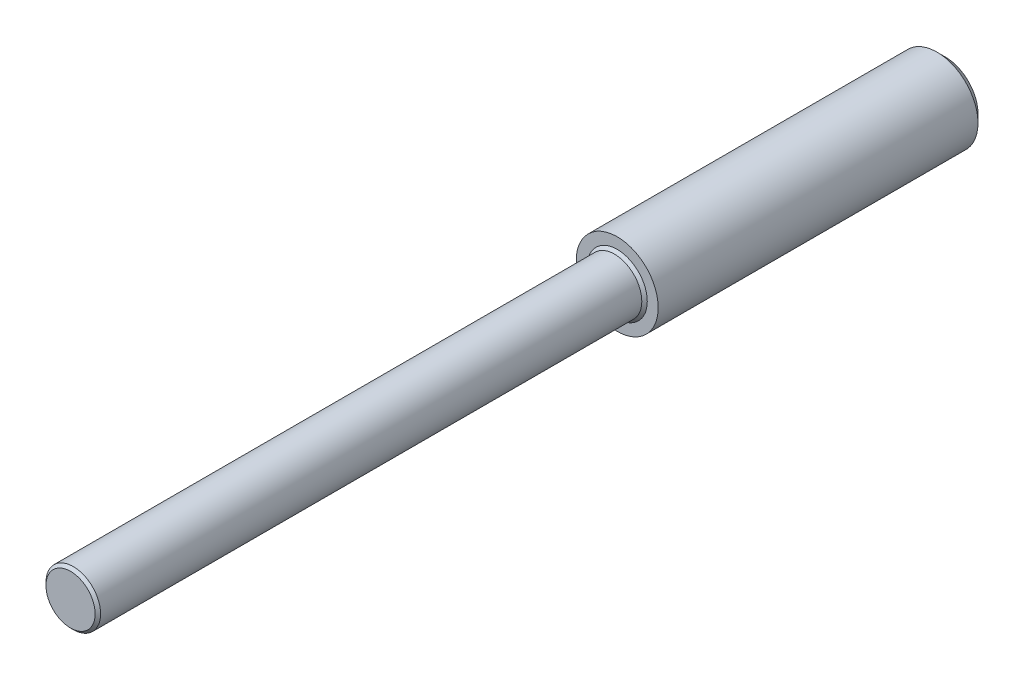
from build123d import *

# Parameters (mm, degrees)
SKETCH1_R           = 1.5
BOSS_EXTRUDE1_DEPTH = 12
SKETCH2_R           = 1
BOSS_EXTRUDE2_DEPTH = 20
CHAMFER1_SIZE       = 0.3
CHAMFER2_SIZE       = 0.1


with BuildPart() as part:
    # Sketch1 → Boss-Extrude1 (new body)
    with BuildSketch(Plane.XY):
        Circle(SKETCH1_R)
    extrude(amount=BOSS_EXTRUDE1_DEPTH)

    # Sketch2 → Boss-Extrude2 (add)
    with BuildSketch(Plane.XY.offset(12)):
        Circle(SKETCH2_R)
    extrude(amount=BOSS_EXTRUDE2_DEPTH)

    # Chamfer1
    chamfer1_edges = [part.edges().sort_by_distance(p)[0] for p in [
        (-1.5, 0, 0),
    ]]
    chamfer(chamfer1_edges, length=CHAMFER1_SIZE)

    # Chamfer2
    chamfer2_edges = [part.edges().sort_by_distance(p)[0] for p in [
        (-1, 0, 12),
        (-1, 0, 32),
    ]]
    chamfer(chamfer2_edges, length=CHAMFER2_SIZE)


solid = part.part
